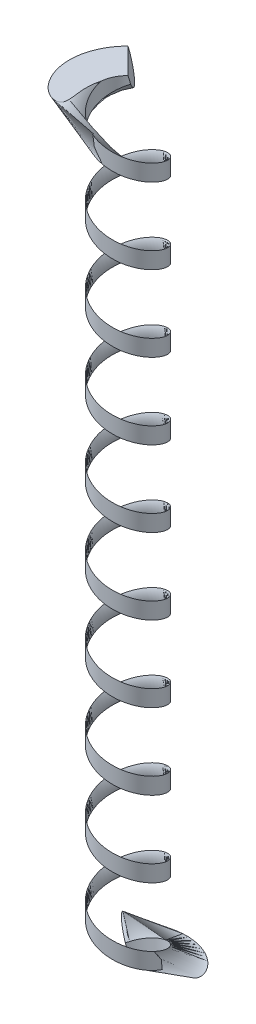
from build123d import *

# Parameters (mm, degrees)
SWEEP1_PITCH            = 5.08
SWEEP1_HEIGHT           = 50.8
SWEEP1_RADIUS           = 3.175
SWEEP1_START_ANGLE      = -135
SWEEP1_PROFILE_R        = 1.27
SKETCH10_W              = 16.053022331
SKETCH10_H              = 5.648285635
SKETCH10_W_2            = 16.112477969
SKETCH10_H_2            = 4.696995423
CUT_EXTRUDE1_DEPTH      = 53.409085496
CUT_EXTRUDE1_DEPTH_BACK = 53.409085496
SKETCH13_R              = 2.019009335
CUT_EXTRUDE3_DEPTH      = 52.187460175
CUT_EXTRUDE3_DEPTH_BACK = 52.187460175


with BuildPart() as part:
    # Sweep1: sweep along a helix
    with BuildLine() as sweep1_path:
        add(Helix(SWEEP1_PITCH, SWEEP1_HEIGHT, SWEEP1_RADIUS, center=(0, 0, 0), direction=(0, 1, 0), lefthand=True, mode=Mode.PRIVATE).rotate(Axis((0, 0, 0), (0, 1, 0)), SWEEP1_START_ANGLE))
    # Sweep1 profile (on start of the path) → Sweep1 (sweep)
    with BuildSketch(Plane(origin=(-2.24506403, 0, -2.24506403), x_dir=(-0.7071067811865477, 0, -0.7071067811865474), z_dir=(0.6852383970326328, 0.24677252372234512, -0.6852383970326331))):
        Circle(SWEEP1_PROFILE_R)
    sweep(path=sweep1_path.line, is_frenet=True)

    # Sketch10 → Cut-Extrude1 (cut, two sides)
    with BuildSketch(Plane(origin=(0, 0, 0), x_dir=(0, 0, -1), z_dir=(1, 0, 0))) as cut_extrude1_sk:
        with Locations((2.245064031, 53.624142818)):
            Rectangle(SKETCH10_W, SKETCH10_H)
        with Locations((0.75508272, -2.348497712)):
            Rectangle(SKETCH10_W_2, SKETCH10_H_2)
    extrude(amount=CUT_EXTRUDE1_DEPTH, mode=Mode.SUBTRACT)
    extrude(cut_extrude1_sk.sketch, amount=-CUT_EXTRUDE1_DEPTH_BACK, mode=Mode.SUBTRACT)

    # Sketch13 → Cut-Extrude3 (cut, two sides)
    with BuildSketch(Plane(origin=(0, 0, 0), x_dir=(1, 0, 0), z_dir=(0, 1, 0))) as cut_extrude3_sk:
        Circle(SKETCH13_R)
    extrude(amount=CUT_EXTRUDE3_DEPTH, mode=Mode.SUBTRACT)
    extrude(cut_extrude3_sk.sketch, amount=-CUT_EXTRUDE3_DEPTH_BACK, mode=Mode.SUBTRACT)


solid = part.part
